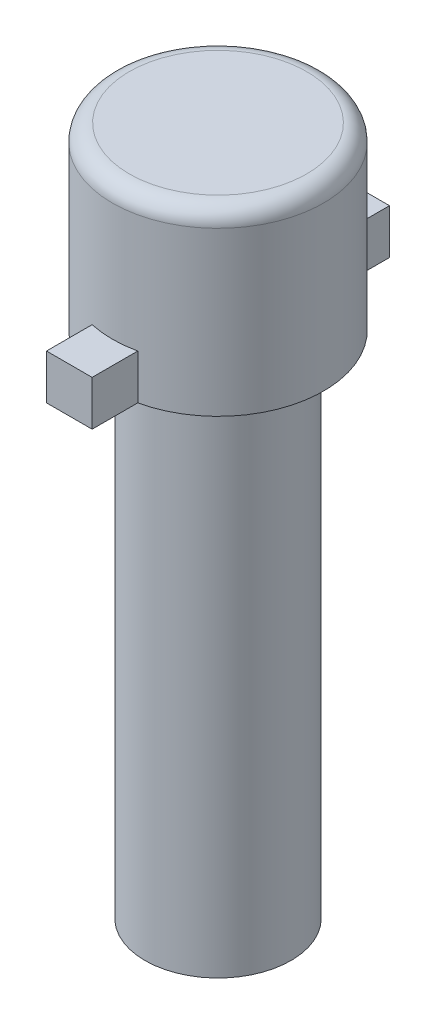
from build123d import *

# Parameters (mm, degrees)
SKETCH1_R           = 3.25
BOSS_EXTRUDE1_DEPTH = 22.686
SKETCH6_R           = 4.7
BOSS_EXTRUDE2_DEPTH = 8
FILLET1_R           = 0.75
BOSS_EXTRUDE3_DEPTH = 2


with BuildPart() as part:
    # Sketch1 → Boss-Extrude1 (new body)
    with BuildSketch(Plane(origin=(0, 0, 0), x_dir=(1, 0, 0), z_dir=(0, 1, 0))):
        Circle(SKETCH1_R)
    extrude(amount=BOSS_EXTRUDE1_DEPTH)

    # Sketch6 → Boss-Extrude2 (add)
    with BuildSketch(Plane(origin=(0, 22.686, 0), x_dir=(1, 0, 0), z_dir=(0, 1, 0))):
        Circle(SKETCH6_R)
    extrude(amount=BOSS_EXTRUDE2_DEPTH)

    # Fillet1
    fillet1_edges = [part.edges().sort_by_distance(p)[0] for p in [
        (-4.7, 30.686, 0),
    ]]
    fillet(fillet1_edges, radius=FILLET1_R)

    # Sketch7 → Boss-Extrude3 (add)
    with BuildSketch(Plane.XZ.offset(-22.686)):
        with BuildLine():
            Line((-1.016, 4.588871757), (-1.016, 6.620871757))
            Line((-1.016, 6.620871757), (1.016, 6.620871757))
            Line((1.016, 6.620871757), (1.016, 4.588871757))
            ThreePointArc((1.016, 4.588871757), (0, 4.7), (-1.016, 4.588871757))
        make_face()
        with BuildLine():
            Line((1.016, -6.620871757), (1.016, -4.588871757))
            ThreePointArc((1.016, -4.588871757), (0, -4.7), (-1.016, -4.588871757))
            Line((-1.016, -4.588871757), (-1.016, -6.620871757))
            Line((-1.016, -6.620871757), (1.016, -6.620871757))
        make_face()
    extrude(amount=-BOSS_EXTRUDE3_DEPTH)


solid = part.part
